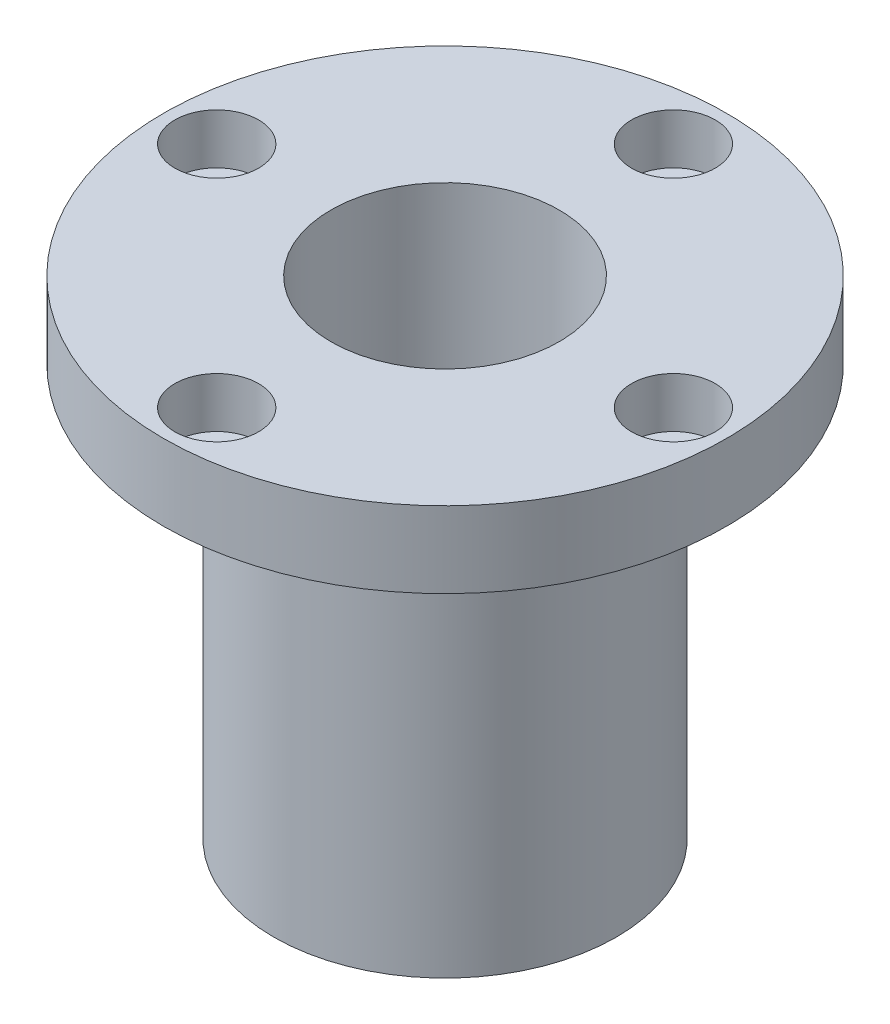
from build123d import *

# Parameters (mm, degrees)
SKETCH_1_R          = 22.5
SKETCH_1_R_2        = 15
EXTRUDE_1_DEPTH     = 64
SKETCH_2_R          = 37
SKETCH_2_R_2        = 22.5
EXTRUDE_2_DEPTH     = 10
SKETCH_3_R          = 5.5
CUT_EXTRUDE_1_DEPTH = 6.6
SKETCH_4_R          = 3.3
CUT_EXTRUDE_2_DEPTH = 65


with BuildPart() as part:
    # 草图1 → 凸台-拉伸1 (new body)
    with BuildSketch(Plane(origin=(0, 0, 0), x_dir=(1, 0, 0), z_dir=(0, 1, 0))):
        Circle(SKETCH_1_R)
        Circle(SKETCH_1_R_2, mode=Mode.SUBTRACT)
    extrude(amount=EXTRUDE_1_DEPTH)

    # 草图2 → 凸台-拉伸2 (add)
    with BuildSketch(Plane(origin=(0, 64, 0), x_dir=(1, 0, 0), z_dir=(0, 1, 0))):
        Circle(SKETCH_2_R)
        Circle(SKETCH_2_R_2, mode=Mode.SUBTRACT)
    extrude(amount=-EXTRUDE_2_DEPTH)

    # 草图3 → 切除-拉伸1 (cut)
    with BuildSketch(Plane(origin=(0, 64, 0), x_dir=(1, 0, 0), z_dir=(0, 1, 0))):
        with Locations((0, 30)):
            Circle(SKETCH_3_R)
        with Locations((30, 0)):
            Circle(SKETCH_3_R)
        with Locations((0, -30)):
            Circle(SKETCH_3_R)
        with Locations((-30, 0)):
            Circle(SKETCH_3_R)
    extrude(amount=-CUT_EXTRUDE_1_DEPTH, mode=Mode.SUBTRACT)

    # 草图4 → 切除-拉伸2 (cut, through all)
    with BuildSketch(Plane(origin=(0, 64, 0), x_dir=(1, 0, 0), z_dir=(0, 1, 0))):
        with Locations((0, 30)):
            Circle(SKETCH_4_R)
        with Locations((30, 0)):
            Circle(SKETCH_4_R)
        with Locations((0, -30)):
            Circle(SKETCH_4_R)
        with Locations((-30, 0)):
            Circle(SKETCH_4_R)
    extrude(amount=-CUT_EXTRUDE_2_DEPTH, mode=Mode.SUBTRACT)


solid = part.part
